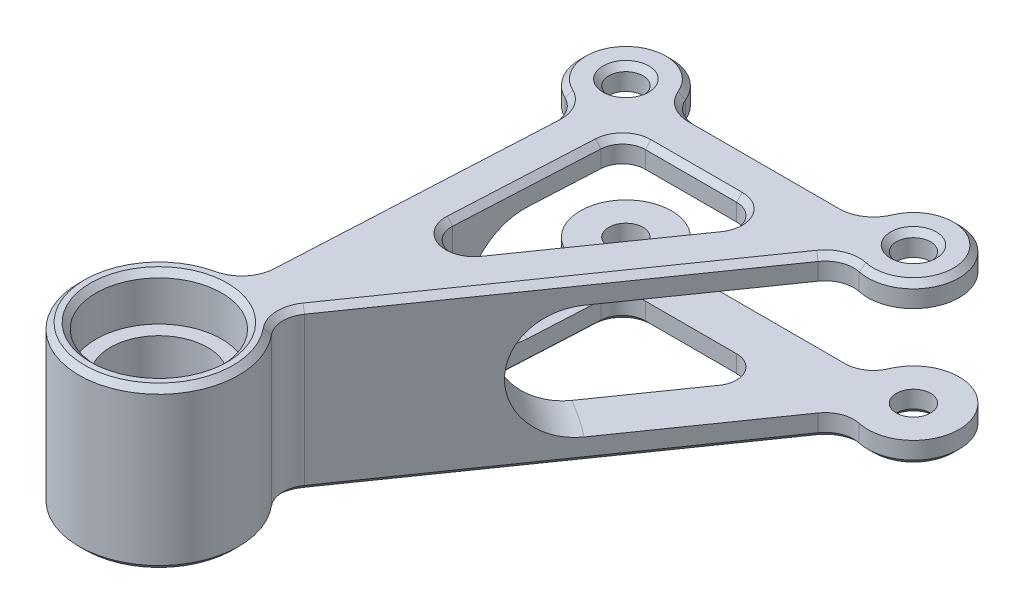
from build123d import *

# Parameters (mm, degrees)
SKETCH1_R                       = 14
BOSS_EXTRUDE1_DEPTH             = 14
SKETCH4_R                       = 11
CUT_EXTRUDE1_DEPTH              = 8
SKETCH5_R                       = 8.5
CUT_EXTRUDE2_DEPTH              = 21
BOSS_EXTRUDE2_REACH             = 16
BOSS_EXTRUDE2_DIRECTION_2_REACH = 16
SKETCH8_R                       = 3
CUT_EXTRUDE3_DEPTH              = 15
CUT_EXTRUDE3_DEPTH_BACK         = 15
FILLET1_R                       = 5
FILLET2_R                       = 4
CHAMFER1_SIZE                   = 1


with BuildPart() as part:
    # Sketch1 → Boss-Extrude1 (new body, symmetric)
    with BuildSketch(Plane(origin=(0, 0, 0), x_dir=(1, 0, 0), z_dir=(0, 1, 0))):
        Circle(SKETCH1_R)
    extrude(amount=BOSS_EXTRUDE1_DEPTH, both=True)

    # Sketch4 → Cut-Extrude1 (cut)
    with BuildSketch(Plane(origin=(0, 14, 0), x_dir=(1, 0, 0), z_dir=(0, 1, 0))):
        Circle(SKETCH4_R)
    cut_extrude1 = extrude(amount=-CUT_EXTRUDE1_DEPTH, mode=Mode.SUBTRACT)

    # Mirror1: Cut-Extrude1 across plane
    add(cut_extrude1.mirror(Plane.ZX), mode=Mode.SUBTRACT)

    # Sketch5 → Cut-Extrude2 (cut, through all)
    with BuildSketch(Plane(origin=(0, 6, 0), x_dir=(1, 0, 0), z_dir=(0, 1, 0))):
        Circle(SKETCH5_R)
    extrude(amount=-CUT_EXTRUDE2_DEPTH, mode=Mode.SUBTRACT)

    # Boss-Extrude2: up to this face of the body (flat: up to its plane)
    boss_extrude2_end = Plane(part.part.faces().sort_by_distance((-13.604020203, 14, 0))[0])
    # Sketch6 → Boss-Extrude2 (add, up to the picked face)
    with BuildSketch(Plane(origin=(0, 0, 0), x_dir=(1, 0, 0), z_dir=(0, 1, 0)), mode=Mode.PRIVATE) as boss_extrude2_sk1:
        with BuildLine():
            Line((0, 0), (49.796956955, 71.339071188))
            ThreePointArc((49.796956955, 71.339071188), (61.469373279, 81.598158377), (46.37598748, 77.89898578))
            Line((46.37598748, 77.89898578), (11.968376795, 77.89898578))
            ThreePointArc((11.968376795, 77.89898578), (-1.542698235, 83.697955691), (3.56136379, 69.909346213))
            Line((3.56136379, 69.909346213), (0, 0))
        make_face()
        Polygon((9.409062598, 27.456171423), (39.035506627, 69.89898578), (11.57120987, 69.89898578), align=None, mode=Mode.SUBTRACT)
    boss_extrude2_tool1 = split(extrude(boss_extrude2_sk1.sketch, amount=BOSS_EXTRUDE2_REACH, mode=Mode.PRIVATE), bisect_by=boss_extrude2_end, keep=Keep.BOTH, mode=Mode.PRIVATE)
    add(boss_extrude2_tool1.solids().sort_by_distance((2.865029, 0, -34.899434))[0])

    # Boss-Extrude2 direction 2: up to this face of the body (flat: up to its plane)
    boss_extrude2_direction_2_end = Plane(part.part.faces().sort_by_distance((-13.604020203, -14, 0))[0])
    # Sketch6 → Boss-Extrude2 direction 2 (add, up to the picked face)
    with BuildSketch(Plane(origin=(0, 0, 0), x_dir=(1, 0, 0), z_dir=(0, 1, 0)), mode=Mode.PRIVATE) as boss_extrude2_direction_2_sk1:
        with BuildLine():
            Line((0, 0), (49.796956955, 71.339071188))
            ThreePointArc((49.796956955, 71.339071188), (61.469373279, 81.598158377), (46.37598748, 77.89898578))
            Line((46.37598748, 77.89898578), (11.968376795, 77.89898578))
            ThreePointArc((11.968376795, 77.89898578), (-1.542698235, 83.697955691), (3.56136379, 69.909346213))
            Line((3.56136379, 69.909346213), (0, 0))
        make_face()
        Polygon((9.409062598, 27.456171423), (39.035506627, 69.89898578), (11.57120987, 69.89898578), align=None, mode=Mode.SUBTRACT)
    boss_extrude2_direction_2_tool1 = split(extrude(boss_extrude2_direction_2_sk1.sketch, amount=-BOSS_EXTRUDE2_DIRECTION_2_REACH, mode=Mode.PRIVATE), bisect_by=boss_extrude2_direction_2_end, keep=Keep.BOTH, mode=Mode.PRIVATE)
    add(boss_extrude2_direction_2_tool1.solids().sort_by_distance((2.865029, 0, -34.899434))[0])

    # Sketch7 → Cut-Revolve1 (revolve, cut)
    with BuildSketch(Plane.XY):
        Polygon((0, 14), (0, -14), (11, -14), (11, -6), (8.5, -6), (8.5, 6), (11, 6), (11, 14), align=None)
    revolve(axis=Axis((0, 14, 0), (0, -1, 0)), mode=Mode.SUBTRACT)

    # Sketch8 → Cut-Extrude3 (cut, two sides)
    with BuildSketch(Plane(origin=(0, 0, 0), x_dir=(1, 0, 0), z_dir=(0, 1, 0))) as cut_extrude3_sk:
        with Locations((3.968376795, 77.89898578)):
            Circle(SKETCH8_R)
        with Locations((54.37598748, 77.89898578)):
            Circle(SKETCH8_R)
    extrude(amount=CUT_EXTRUDE3_DEPTH, mode=Mode.SUBTRACT)
    extrude(cut_extrude3_sk.sketch, amount=-CUT_EXTRUDE3_DEPTH_BACK, mode=Mode.SUBTRACT)

    # Fillet1
    fillet1_edges = [part.edges().sort_by_distance(p)[0] for p in [
        (8.013303418, 0, -11.479850536),
        (0.712272758, 0, -13.981869243),
        (3.56136379, 0, -69.909346213),
        (11.968376795, 0, -77.89898578),
        (46.37598748, 0, -77.89898578),
        (49.796956955, 0, -71.339071188),
    ]]
    fillet(fillet1_edges, radius=FILLET1_R)

    # Fillet2
    fillet2_edges = [part.edges().sort_by_distance(p)[0] for p in [
        (11.57120987, 0, -69.89898578),
        (39.035506627, 0, -69.89898578),
        (9.409062598, 0, -27.456171423),
    ]]
    fillet(fillet2_edges, radius=FILLET2_R)

    # Sketch10 → Cut-Revolve2 (revolve, cut)
    with BuildSketch(Plane.ZY.offset(4.031623205)):
        with BuildLine():
            Line((-115.89898578, 10), (-55.89898578, 10))
            ThreePointArc((-55.89898578, 10), (-45.89898578, 0), (-55.89898578, -10))
            Line((-55.89898578, -10), (-115.89898578, -10))
            Line((-115.89898578, -10), (-115.89898578, 10))
        make_face()
    revolve(axis=Axis((-4.031623205, 14, 0.161756304), (0, -1, 0)), mode=Mode.SUBTRACT)

    # Chamfer1
    chamfer1_edges = [part.edges().sort_by_distance(p)[0] for p in [
        (45.149488461, -14, -78.738734309),
        (45.149488461, 14, -78.738734309),
        (13.194875814, -14, -78.738734309),
        (13.194875814, 14, -78.738734309),
        (26.019387345, 14, -51.252106195),
        (26.019387345, -14, -51.252106195),
        (23.368946304, 14, -69.89898578),
        (23.368946304, -14, -69.89898578),
        (10.748290369, 14, -53.74512796),
        (10.748290369, -14, -53.74512796),
        (34.9119591, -14, -67.748572079),
        (34.9119591, 14, -67.748572079),
        (12.617088893, -14, -68.798470735),
        (12.617088893, 14, -68.798470735),
        (12.81684933, -14, -37.400283889),
        (12.81684933, 14, -37.400283889),
        (-6.296166971, -14, 9.019882564),
        (-6.296166971, 14, 9.019882564),
        (0.968376795, -14, -77.89898578),
        (0.968376795, 14, -77.89898578),
        (51.37598748, -14, -77.89898578),
        (51.37598748, 14, -77.89898578),
        (28.999659343, 14, -41.544883239),
        (28.999659343, -14, -41.544883239),
        (-4.538605987, 14, 13.243906361),
        (-4.538605987, -14, 13.243906361),
        (2.14522062, -14, -42.110545238),
        (2.14522062, 14, -42.110545238),
        (-1.542698235, 14, -83.697955691),
        (-1.542698235, -14, -83.697955691),
        (61.469373279, 14, -81.598158377),
        (61.469373279, -14, -81.598158377),
        (29.172182137, 14, -77.89898578),
        (29.172182137, -14, -77.89898578),
        (9.596412617, -14, -11.95458808),
        (9.596412617, 14, -11.95458808),
        (-0.246894433, 14, -15.32782941),
        (-0.246894433, -14, -15.32782941),
        (2.66030265, -14, -68.727159148),
        (2.66030265, 14, -68.727159148),
        (49.783519727, -14, -69.852700819),
        (49.783519727, 14, -69.852700819),
    ]]
    chamfer(chamfer1_edges, length=CHAMFER1_SIZE)


solid = part.part
